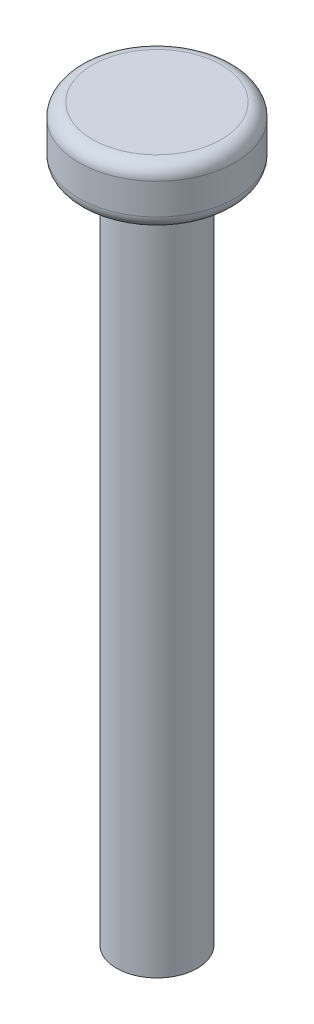
from build123d import *

# Parameters (mm, degrees)
SKETCH1_R           = 3
BOSS_EXTRUDE1_DEPTH = 50
SKETCH2_R           = 5.8
BOSS_EXTRUDE2_DEPTH = 4.3
FILLET1_R           = 1


with BuildPart() as part:
    # Sketch1 → Boss-Extrude1 (new body)
    with BuildSketch(Plane(origin=(0, 0, 0), x_dir=(1, 0, 0), z_dir=(0, 1, 0))):
        with Locations(Location((0, 0, 0), (0, 0, 270))):  # turned: the seam where the file's is
            Circle(SKETCH1_R)
    extrude(amount=BOSS_EXTRUDE1_DEPTH)

    # Sketch2 → Boss-Extrude2 (add)
    with BuildSketch(Plane(origin=(0, 50, 0), x_dir=(1, 0, 0), z_dir=(0, 1, 0))):
        with Locations(Location((0, 0, 0), (0, 0, 270))):  # turned: the seam where the file's is
            Circle(SKETCH2_R)
    extrude(amount=BOSS_EXTRUDE2_DEPTH)

    # Fillet1
    fillet1_edges = [part.edges().sort_by_distance(p)[0] for p in [
        (0, 50, -5.8),
        (0, 54.3, -5.8),
    ]]
    fillet(fillet1_edges, radius=FILLET1_R)


solid = part.part
